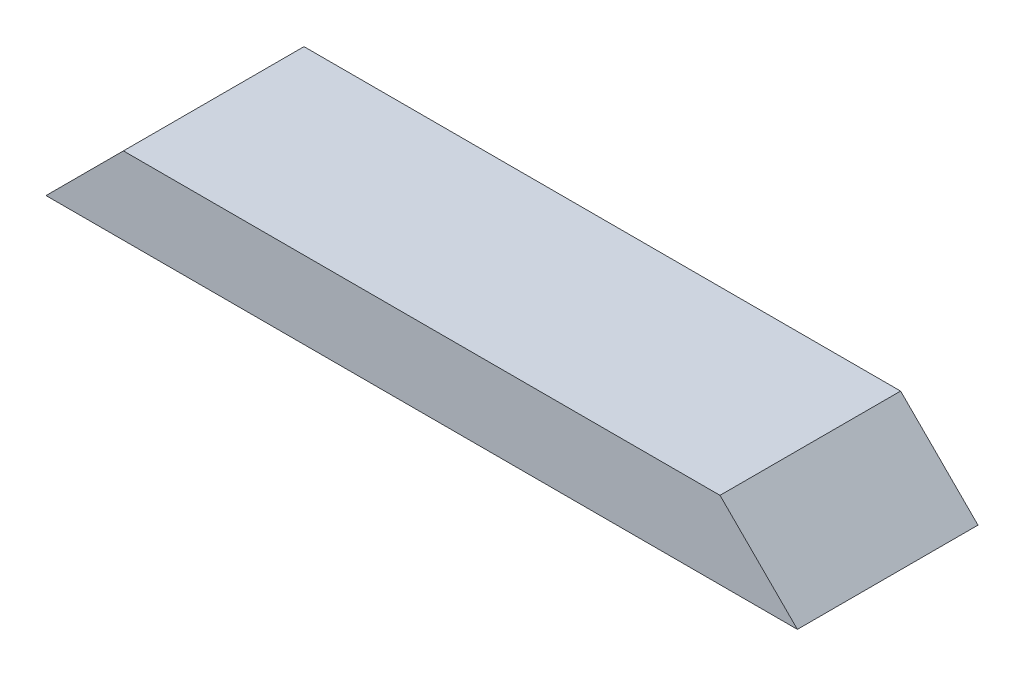
from build123d import *

# Parameters (mm, degrees)
SKETCH1_W           = 369.8875
SKETCH1_H           = 88.9
BOSS_EXTRUDE1_DEPTH = 38.1
CUT_EXTRUDE1_DEPTH  = 89.9


with BuildPart() as part:
    # Sketch1 → Boss-Extrude1 (new body)
    with BuildSketch(Plane(origin=(0, 0, 0), x_dir=(1, 0, 0), z_dir=(0, 1, 0))):
        with Locations((184.94375, 44.45)):
            Rectangle(SKETCH1_W, SKETCH1_H)
    extrude(amount=BOSS_EXTRUDE1_DEPTH)

    # Sketch2 → Cut-Extrude1 (cut, through all)
    with BuildSketch(Plane.XY):
        Polygon((0, 0), (38.1, 38.1), (0, 38.1), align=None)
        Polygon((369.8875, 0), (369.8875, 38.1), (331.7875, 38.1), align=None)
    extrude(amount=-CUT_EXTRUDE1_DEPTH, mode=Mode.SUBTRACT)


solid = part.part
